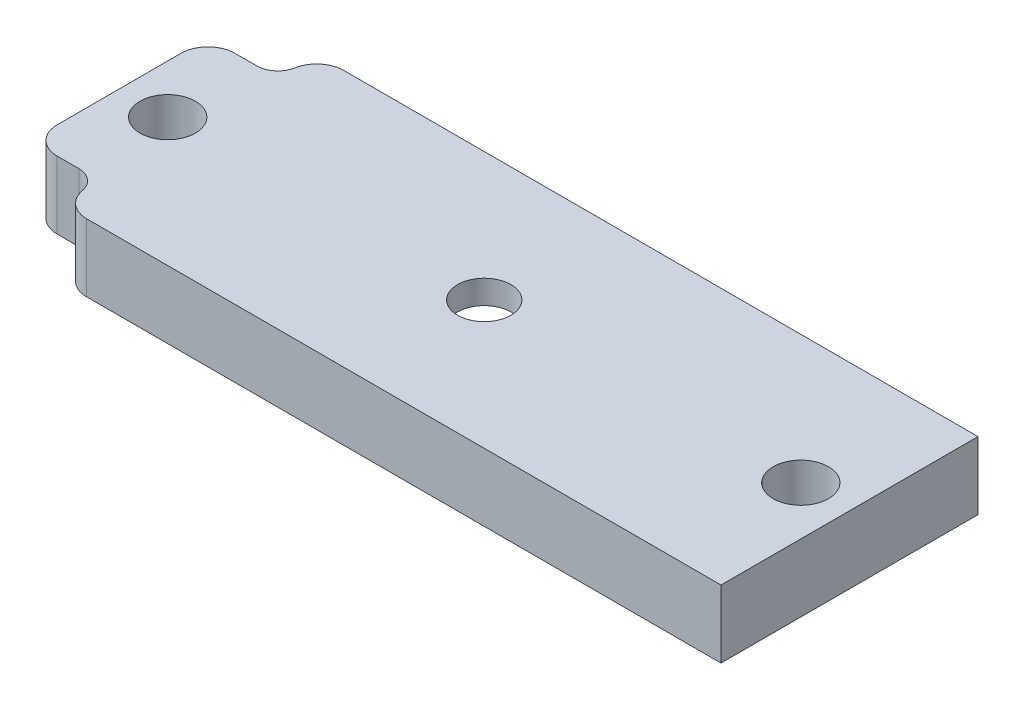
from build123d import *

# Parameters (mm, degrees)
SKETCH2_W           = 68.58
SKETCH2_H           = 24.13
SKETCH2_R           = 2.6
BOSS_EXTRUDE1_DEPTH = 6.35
CUT_EXTRUDE1_DEPTH  = 7.35
FILLET3_R           = 2.54
SKETCH4_R           = 2.5
CUT_EXTRUDE2_DEPTH  = 7.3500001


with BuildPart() as part:
    # Sketch2 → Boss-Extrude1 (new body)
    with BuildSketch(Plane(origin=(0, 0, 0), x_dir=(1, 0, 0), z_dir=(0, 1, 0))):
        with Locations((34.29, 12.065)):
            Rectangle(SKETCH2_W, SKETCH2_H)
        with Locations((4.57, 12.065)):
            Circle(SKETCH2_R, mode=Mode.SUBTRACT)
        with Locations((64.01, 12.065)):
            Circle(SKETCH2_R, mode=Mode.SUBTRACT)
    extrude(amount=BOSS_EXTRUDE1_DEPTH)

    # Sketch3 → Cut-Extrude1 (cut, through all)
    with BuildSketch(Plane(origin=(0, 6.35, 0), x_dir=(1, 0, 0), z_dir=(0, 1, 0))):
        with BuildLine():
            Line((4.57, 3.715), (0, 3.715))
            Line((0, 3.715), (0, 0))
            Line((0, 0), (6.57, 0))
            Line((6.57, 0), (6.57, 1.715))
            ThreePointArc((6.57, 1.715), (5.984213562, 3.129213562), (4.57, 3.715))
        make_face()
        with BuildLine():
            ThreePointArc((4.57, 20.415), (5.984213562, 21.000786438), (6.57, 22.415))
            Line((6.57, 22.415), (6.57, 24.13))
            Line((6.57, 24.13), (0, 24.13))
            Line((0, 24.13), (0, 20.415))
            Line((0, 20.415), (4.57, 20.415))
        make_face()
    extrude(amount=-CUT_EXTRUDE1_DEPTH, mode=Mode.SUBTRACT)

    # Fillet3
    fillet3_edges = [part.edges().sort_by_distance(p)[0] for p in [
        (6.57, 3.175, 0),
        (0, 3.175, -3.715),
        (0, 3.175, -20.415),
        (6.57, 3.175, -24.13),
    ]]
    fillet(fillet3_edges, radius=FILLET3_R)

    # Sketch4 → Cut-Extrude2 (cut, through all)
    with BuildSketch(Plane(origin=(0, 6.35, 0), x_dir=(1, 0, 0), z_dir=(0, 1, 0))):
        with Locations((34.29, 12.065)):
            Circle(SKETCH4_R)
    extrude(amount=-CUT_EXTRUDE2_DEPTH, mode=Mode.SUBTRACT)

    # Sketch8 one side → Cut-Revolve6 (revolve, cut)
    with BuildSketch(Plane(origin=(34.29, 0, 0), x_dir=(0, 0, -1), z_dir=(1, 0, 0))):
        with BuildLine():
            Line((12.065, 0), (22.13, 0))
            ThreePointArc((22.13, 0), (17.5473974, 3.215969501), (12.065, 4.35))
            Line((12.065, 4.35), (12.065, 0))
        make_face()
    revolve(axis=Axis((34.29, 6.35, -12.065), (0, -1, 0)), mode=Mode.SUBTRACT)


solid = part.part
